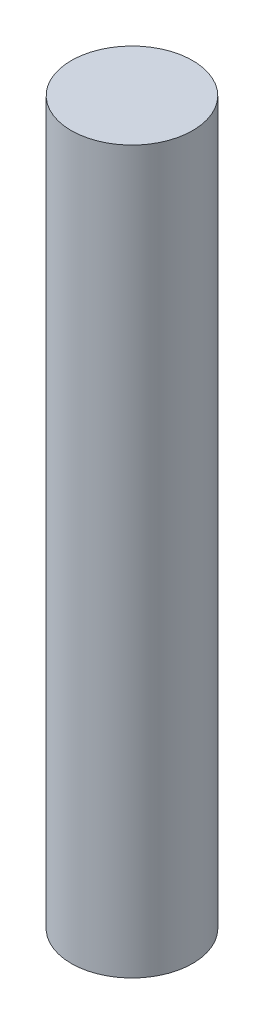
from build123d import *

# Parameters (mm, degrees)
SKETCH1_R           = 3.45
BOSS_EXTRUDE1_DEPTH = 41


with BuildPart() as part:
    # Sketch1 → Boss-Extrude1 (new body)
    with BuildSketch(Plane(origin=(0, 0, 0), x_dir=(1, 0, 0), z_dir=(0, 1, 0))):
        Circle(SKETCH1_R)
    extrude(amount=BOSS_EXTRUDE1_DEPTH)


solid = part.part
